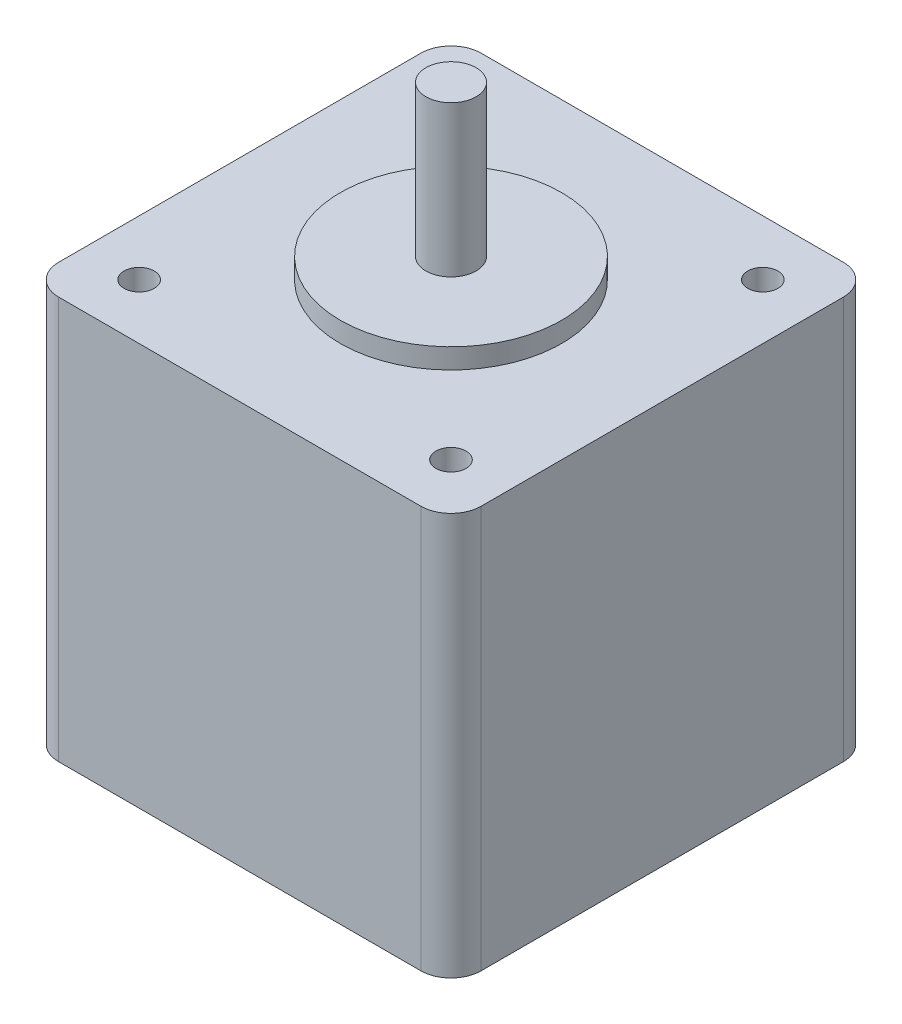
from build123d import *

# Parameters (mm, degrees)
BOSS_EXTRUDE1_DEPTH = 40
SKETCH2_R           = 11
BOSS_EXTRUDE2_DEPTH = 2
SKETCH3_R           = 2.5
BOSS_EXTRUDE3_DEPTH = 15
SKETCH4_R           = 1.5
CUT_EXTRUDE1_DEPTH  = 5


with BuildPart() as part:
    # Sketch1 → Boss-Extrude1 (new body)
    with BuildSketch(Plane(origin=(0, 0, 0), x_dir=(1, 0, 0), z_dir=(0, 1, 0))):
        with BuildLine():
            Line((3, 0), (39, 0))
            ThreePointArc((39, 0), (41.121320344, 0.878679656), (42, 3))
            Line((42, 3), (42, 39))
            ThreePointArc((42, 39), (41.121320344, 41.121320344), (39, 42))
            Line((39, 42), (3, 42))
            ThreePointArc((3, 42), (0.878679656, 41.121320344), (0, 39))
            Line((0, 39), (0, 3))
            ThreePointArc((0, 3), (0.878679656, 0.878679656), (3, 0))
        make_face()
    extrude(amount=BOSS_EXTRUDE1_DEPTH)

    # Sketch2 → Boss-Extrude2 (add)
    with BuildSketch(Plane(origin=(0, 40, 0), x_dir=(1, 0, 0), z_dir=(0, 1, 0))):
        with Locations((21, 21)):
            Circle(SKETCH2_R)
    extrude(amount=BOSS_EXTRUDE2_DEPTH)

    # Sketch3 → Boss-Extrude3 (add)
    with BuildSketch(Plane(origin=(0, 42, 0), x_dir=(1, 0, 0), z_dir=(0, 1, 0))):
        with Locations((21, 21)):
            Circle(SKETCH3_R)
    extrude(amount=BOSS_EXTRUDE3_DEPTH)

    # Sketch4 → Cut-Extrude1 (cut)
    with BuildSketch(Plane(origin=(0, 40, 0), x_dir=(1, 0, 0), z_dir=(0, 1, 0))):
        with Locations((5.5, 36.5)):
            Circle(SKETCH4_R)
        with Locations((36.5, 36.5)):
            Circle(SKETCH4_R)
        with Locations((36.5, 5.5)):
            Circle(SKETCH4_R)
        with Locations((5.5, 5.5)):
            Circle(SKETCH4_R)
    extrude(amount=-CUT_EXTRUDE1_DEPTH, mode=Mode.SUBTRACT)


solid = part.part
